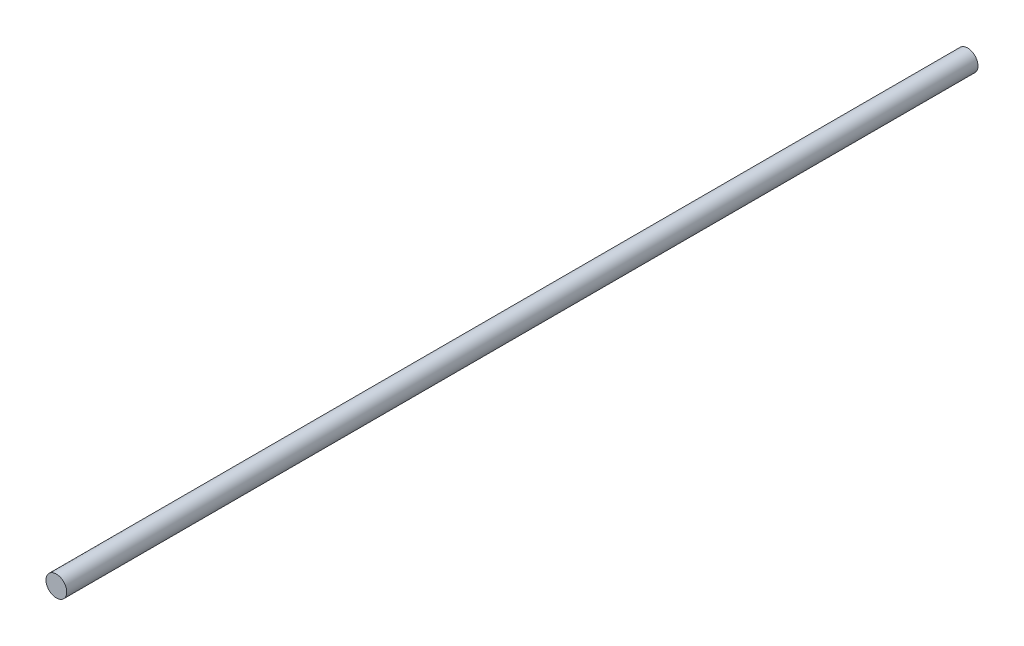
from build123d import *

# Parameters (mm, degrees)
SKETCH_2_R      = 2.051971833
EXTRUDE_1_DEPTH = 180


with BuildPart() as part:
    # 草图2 → 凸台-拉伸1 (new body)
    with BuildSketch(Plane.XY):
        Circle(SKETCH_2_R)
    extrude(amount=EXTRUDE_1_DEPTH)


solid = part.part
